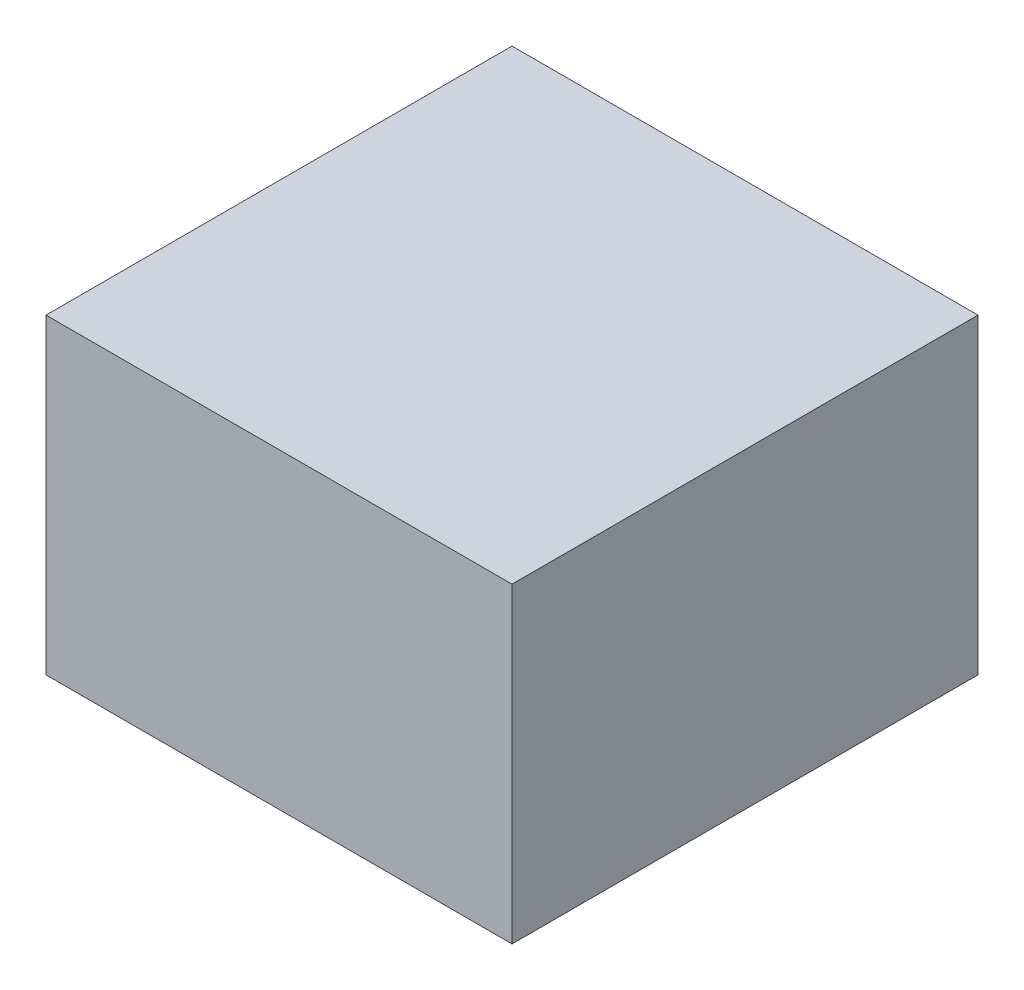
from build123d import *

# Parameters (mm, degrees)
SKETCH1_W           = 67
SKETCH1_H           = 67
BOSS_EXTRUDE1_DEPTH = 22.4


with BuildPart() as part:
    # Sketch1 → Boss-Extrude1 (new body, symmetric)
    with BuildSketch(Plane(origin=(0, 0, 0), x_dir=(1, 0, 0), z_dir=(0, 1, 0))):
        with Locations((-5, 5)):
            Rectangle(SKETCH1_W, SKETCH1_H)
    extrude(amount=BOSS_EXTRUDE1_DEPTH, both=True)


solid = part.part
